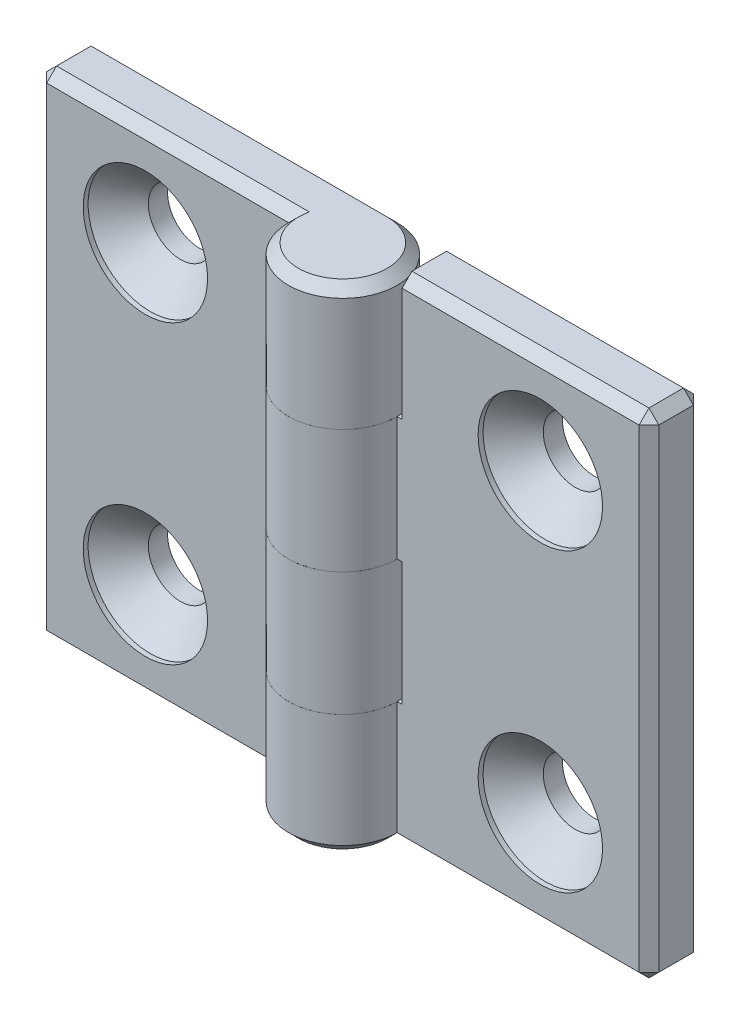
from build123d import *

# Parameters (mm, degrees)
EXTRUDE_1_DEPTH            = 25
SKETCH_3_W                 = 11.5
SKETCH_3_H                 = 12.5
CUT_EXTRUDE_1_DEPTH        = 6.5
CUT_EXTRUDE_1_DEPTH_BACK   = 6.5
HOLE_WIZARD_M61_AT_2_COUNT = 2
HOLE_WIZARD_M61_AT_2_PITCH = 30
CHAMFER_1_SIZE             = 1
PATTERN_CIRCULAR_1_COUNT   = 2


with BuildPart() as part:
    # Эскиз1 → Бобышка-Вытянуть1 (new body, symmetric)
    with BuildSketch(Plane(origin=(0, 0, 0), x_dir=(1, 0, 0), z_dir=(0, 1, 0))):
        with BuildLine():
            Line((0, 5.5), (-31, 5.5))
            Line((-31, 5.5), (-31, 0))
            Line((-31, 0), (-5.5, 0))
            ThreePointArc((-5.5, 0), (3.889087297, -3.889087297), (0, 5.5))
        make_face()
    extrude(amount=EXTRUDE_1_DEPTH, both=True)

    # Эскиз3 → Вырез-Вытянуть1 (cut, two sides)
    with BuildSketch(Plane.XY) as cut_extrude_1_sk:
        with Locations((-0.25, 6.25)):
            Rectangle(SKETCH_3_W, SKETCH_3_H)
        with Locations((-0.25, -18.75)):
            Rectangle(SKETCH_3_W, SKETCH_3_H)
    extrude(amount=CUT_EXTRUDE_1_DEPTH, mode=Mode.SUBTRACT)
    extrude(cut_extrude_1_sk.sketch, amount=-CUT_EXTRUDE_1_DEPTH_BACK, mode=Mode.SUBTRACT)

    # Эскиз6 → Зенковка для винта с полупотайной головкой M61 (revolve, cut)
    with BuildSketch(Plane(origin=(-20, 15, 0), x_dir=(0, -1, 0), z_dir=(1, 0, 0))):
        Polygon((0, 0), (0, 5.5), (3.25, 5.5), (3.25, 3.55), (6.3, 0.5), (6.3, 0), align=None)
    hole_wizard_m61 = revolve(axis=Axis((-20, 15, 6.35), (0, 0, -1)), mode=Mode.SUBTRACT)

    # Зенковка для винта с полупотайной головкой M61 at 2: Зенковка для винта с полупотайной головкой M61 ×2
    with Locations(*[(0, -i * HOLE_WIZARD_M61_AT_2_PITCH, 0) for i in range(1, HOLE_WIZARD_M61_AT_2_COUNT)]):
        add(hole_wizard_m61, mode=Mode.SUBTRACT)

    # Фаска1
    chamfer_1_edges = [part.edges().sort_by_distance(p)[0] for p in [
        (-31, 25, -2.75),
        (-18.5, -25, -5.5),
        (-18.25, 25, 0),
        (3.889087297, 25, 3.889087297),
        (-18.5, -25, 0),
        (-31, -25, -2.75),
        (-31, 0, 0),
        (-31, 0, -5.5),
        (-15.5, 25, -5.5),
    ]]
    chamfer(chamfer_1_edges, length=CHAMFER_1_SIZE)


with BuildPart() as pattern_circular_1_1:
    # Круговой массив1: pattern copy
    add(part.part.rotate(Axis((0, 0, 0), (0, 0, 1)), 1 * 360 / PATTERN_CIRCULAR_1_COUNT))


solid = Compound([part.part, pattern_circular_1_1.part])
